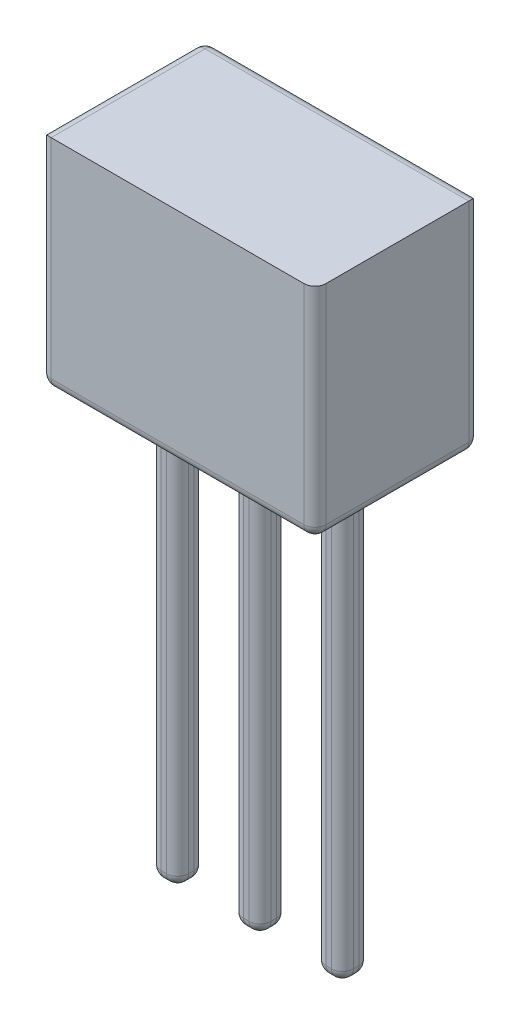
from build123d import *

# Parameters (mm, degrees)
SKETCH1_W           = 5
SKETCH1_H           = 4
BOSS_EXTRUDE1_DEPTH = 3
SKETCH2_W           = 0.5
SKETCH2_H           = 0.5
BOSS_EXTRUDE2_DEPTH = 8
FILLET2_R           = 0.2


with BuildPart() as part:
    # Sketch1 → Boss-Extrude1 (new body)
    with BuildSketch(Plane.XY):
        with Locations((-47.686928434, 20.152823879)):
            Rectangle(SKETCH1_W, SKETCH1_H)
    extrude(amount=BOSS_EXTRUDE1_DEPTH)

    # Sketch2 → Boss-Extrude2 (add)
    with BuildSketch(Plane.XZ.offset(-18.152823879)):
        with Locations((-49.186928434, 1.5)):
            Rectangle(SKETCH2_W, SKETCH2_H)
        with Locations((-47.686928434, 1.5)):
            Rectangle(SKETCH2_W, SKETCH2_H)
        with Locations((-46.186928434, 1.5)):
            Rectangle(SKETCH2_W, SKETCH2_H)
    extrude(amount=BOSS_EXTRUDE2_DEPTH)

    # Fillet2
    fillet2_edges = [part.edges().sort_by_distance(p)[0] for p in [
        (-50.186928434, 20.152823879, 3),
        (-47.686928434, 18.152823879, 3),
        (-49.436928434, 18.152823879, 1.5),
        (-49.436928434, 14.152823879, 1.75),
        (-49.186928434, 18.152823879, 1.25),
        (-49.436928434, 14.152823879, 1.25),
        (-48.936928434, 18.152823879, 1.5),
        (-48.936928434, 14.152823879, 1.25),
        (-49.186928434, 18.152823879, 1.75),
        (-48.936928434, 14.152823879, 1.75),
        (-49.436928434, 10.152823879, 1.5),
        (-49.186928434, 10.152823879, 1.25),
        (-48.936928434, 10.152823879, 1.5),
        (-49.186928434, 10.152823879, 1.75),
        (-47.936928434, 18.152823879, 1.5),
        (-47.936928434, 14.152823879, 1.75),
        (-47.686928434, 18.152823879, 1.25),
        (-47.936928434, 14.152823879, 1.25),
        (-47.436928434, 18.152823879, 1.5),
        (-47.436928434, 14.152823879, 1.25),
        (-47.686928434, 18.152823879, 1.75),
        (-47.436928434, 14.152823879, 1.75),
        (-47.936928434, 10.152823879, 1.5),
        (-47.686928434, 10.152823879, 1.25),
        (-47.436928434, 10.152823879, 1.5),
        (-47.686928434, 10.152823879, 1.75),
        (-46.436928434, 18.152823879, 1.5),
        (-46.436928434, 14.152823879, 1.75),
        (-46.186928434, 18.152823879, 1.25),
        (-46.436928434, 14.152823879, 1.25),
        (-45.936928434, 18.152823879, 1.5),
        (-45.936928434, 14.152823879, 1.25),
        (-46.186928434, 18.152823879, 1.75),
        (-45.936928434, 14.152823879, 1.75),
        (-46.436928434, 10.152823879, 1.5),
        (-46.186928434, 10.152823879, 1.25),
        (-45.936928434, 10.152823879, 1.5),
        (-46.186928434, 10.152823879, 1.75),
        (-45.186928434, 20.152823879, 3),
        (-47.686928434, 18.152823879, 0),
        (-50.186928434, 20.152823879, 0),
        (-47.686928434, 22.152823879, 0),
        (-45.186928434, 20.152823879, 0),
        (-45.186928434, 18.152823879, 1.5),
        (-50.186928434, 18.152823879, 1.5),
        (-50.186928434, 22.152823879, 1.5),
    ]]
    fillet(fillet2_edges, radius=FILLET2_R)


solid = part.part
